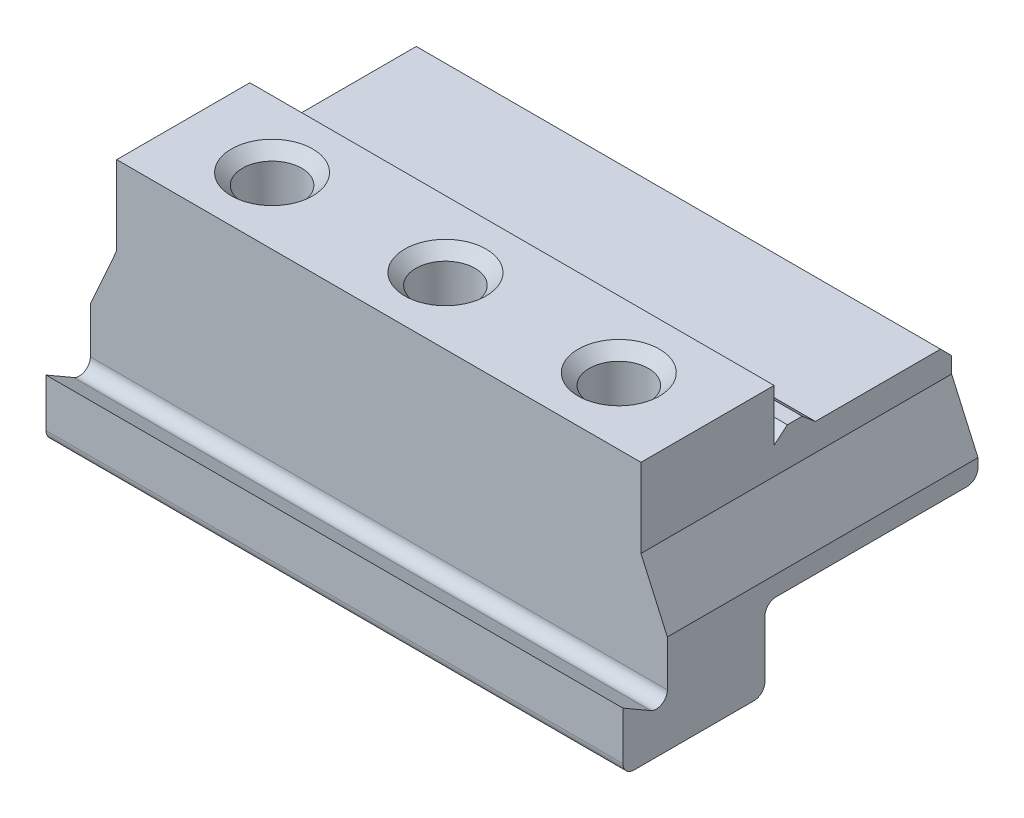
from build123d import *

# Parameters (mm, degrees)
BOSS_EXTRUDE1_DEPTH = 78
CUT_EXTRUDE1_DEPTH  = 78
SKETCH3_R           = 4
CUT_EXTRUDE2_DEPTH  = 10
CHAMFER1_SIZE       = 1.5


with BuildPart() as part:
    # Sketch1 → Boss-Extrude1 (new body)
    with BuildSketch(Plane(origin=(0, 0, 0), x_dir=(0, 0, -1), z_dir=(1, 0, 0))):
        with BuildLine():
            Line((0, 1.5), (0, 8))
            Line((0, 8), (3.75, 5.834936491))
            ThreePointArc((3.75, 5.834936491), (5.25, 5.834936491), (6, 7.133974596))
            Line((6, 7.133974596), (6, 32))
            Line((6, 32), (24, 32))
            Line((24, 32), (24, 25))
            Line((24, 25), (25.787630389, 26.5))
            Line((25.787630389, 26.5), (27.787630389, 26.5))
            Line((27.787630389, 26.5), (29.575260778, 25))
            Line((29.575260778, 25), (46.5, 25))
            Line((46.5, 25), (48, 23.5))
            Line((48, 23.5), (48, 12.17))
            ThreePointArc((48, 12.17), (47.560660172, 11.109339828), (46.5, 10.67))
            Line((46.5, 10.67), (20.7, 10.67))
            ThreePointArc((20.7, 10.67), (19.639339828, 10.230660172), (19.2, 9.17))
            Line((19.2, 9.17), (19.2, 1.5))
            ThreePointArc((19.2, 1.5), (18.760660172, 0.439339828), (17.7, 0))
            Line((17.7, 0), (1.5, 0))
            ThreePointArc((1.5, 0), (0.439339828, 0.439339828), (0, 1.5))
        make_face()
    extrude(amount=BOSS_EXTRUDE1_DEPTH)

    # Sketch2 → Cut-Extrude1 (cut)
    with BuildSketch(Plane.XY.offset(-6)):
        Polygon((78, 17.191886664), (78, 32), (74.438170518, 32), (74.438170518, 21.33), (78, 13.33), align=None)
        Polygon((0, 17.191886664), (0, 13.33), (3.561829482, 21.33), (3.561829482, 32), (0, 32), align=None)
    extrude(amount=-CUT_EXTRUDE1_DEPTH, mode=Mode.SUBTRACT)

    # Sketch3 → Cut-Extrude2 (cut)
    with BuildSketch(Plane(origin=(0, 32, 0), x_dir=(1, 0, 0), z_dir=(0, 1, 0))):
        with Locations((15.561829482, 15)):
            Circle(SKETCH3_R)
        with Locations((39, 15)):
            Circle(SKETCH3_R)
        with Locations((62.438170518, 15)):
            Circle(SKETCH3_R)
    extrude(amount=-CUT_EXTRUDE2_DEPTH, mode=Mode.SUBTRACT)

    # Chamfer1
    chamfer1_edges = [part.edges().sort_by_distance(p)[0] for p in [
        (11.561829482, 32, -15),
        (35, 32, -15),
        (58.438170518, 32, -15),
    ]]
    chamfer(chamfer1_edges, length=CHAMFER1_SIZE)


solid = part.part
